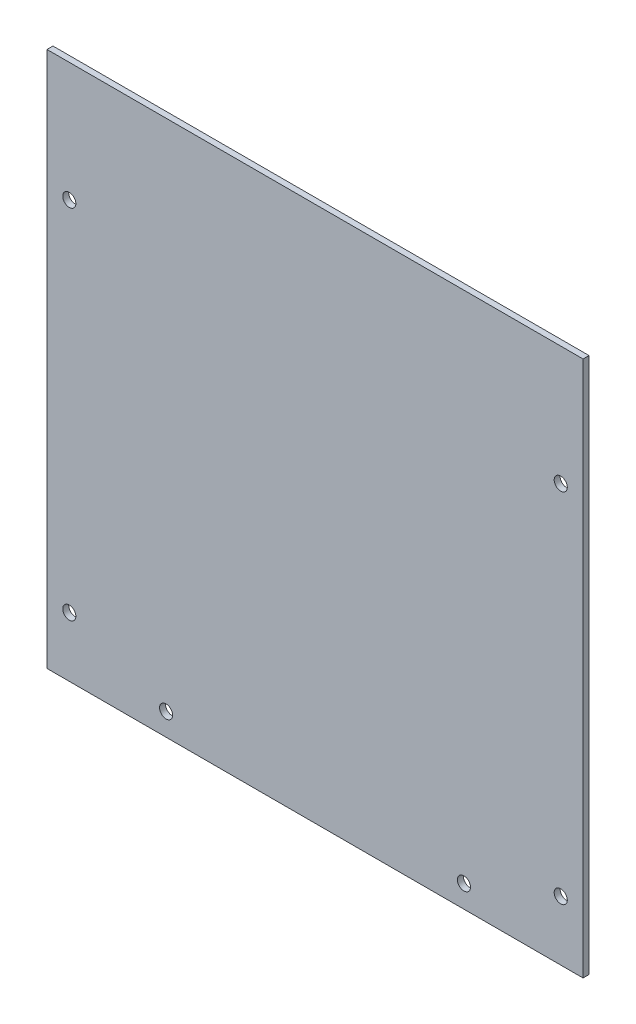
from build123d import *

# Parameters (mm, degrees)
SKETCH_1_W          = 180
SKETCH_1_H          = 180
EXTRUDE_1_DEPTH     = 2
CUT_EXTRUDE_1_DEPTH = 140
SKETCH_3_R          = 2.2
CUT_EXTRUDE_2_DEPTH = 160


with BuildPart() as part:
    # ｽｹｯﾁ1 → ﾎﾞｽ - 押し出し1 (new body)
    with BuildSketch(Plane.XY):
        Rectangle(SKETCH_1_W, SKETCH_1_H)
    extrude(amount=EXTRUDE_1_DEPTH)

    # ｽｹｯﾁ2 → ｶｯﾄ - 押し出し1 (cut)
    with BuildSketch(Plane.XY.offset(2)):
        with BuildLine():
            ThreePointArc((-52.2, -82.5), (-51.555634919, -84.055634919), (-50, -84.7))
            Line((-50, -84.7), (-50, -82.5))
            Line((-50, -82.5), (-52.2, -82.5))
        make_face()
        with BuildLine():
            Line((-50, -82.5), (-50, -84.7))
            ThreePointArc((-50, -84.7), (-48.444365081, -84.055634919), (-47.8, -82.5))
            ThreePointArc((-47.8, -82.5), (-50, -80.3), (-52.2, -82.5))
            Line((-52.2, -82.5), (-50, -82.5))
        make_face()
        with BuildLine():
            ThreePointArc((52.2, -82.5), (48.444365081, -80.944365081), (50, -84.7))
            Line((50, -84.7), (50, -82.5))
            Line((50, -82.5), (52.2, -82.5))
        make_face()
        with BuildLine():
            Line((50, -82.5), (50, -84.7))
            ThreePointArc((50, -84.7), (51.555634919, -84.055634919), (52.2, -82.5))
            Line((52.2, -82.5), (50, -82.5))
        make_face()
    extrude(amount=-CUT_EXTRUDE_1_DEPTH, mode=Mode.SUBTRACT)

    # ｽｹｯﾁ3 → ｶｯﾄ - 押し出し2 (cut)
    with BuildSketch(Plane.XY.offset(2)):
        with Locations((-82.5, 50)):
            Circle(SKETCH_3_R)
        with Locations((82.5, 50)):
            Circle(SKETCH_3_R)
        with Locations((82.5, -70)):
            Circle(SKETCH_3_R)
        with Locations((-82.5, -70)):
            Circle(SKETCH_3_R)
    extrude(amount=-CUT_EXTRUDE_2_DEPTH, mode=Mode.SUBTRACT)


solid = part.part
